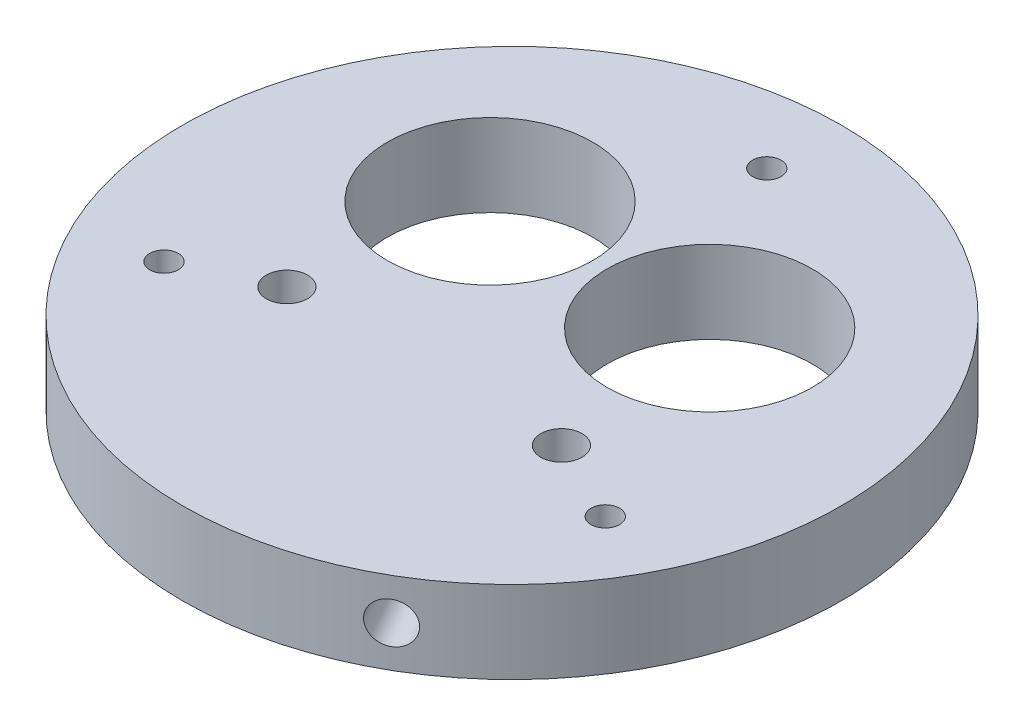
from build123d import *

# Parameters (mm, degrees)
SKETCH1_R               = 38.1127
BOSS_EXTRUDE1_DEPTH     = 9.525
SKETCH2_R               = 1.651
SKETCH2_R_2             = 11.8745
CUT_EXTRUDE1_DEPTH      = 55.734645587
SKETCH4_R               = 2.3749
CUT_EXTRUDE2_DEPTH      = 6.35
CIRPATTERN1_COUNT       = 3
CUT_EXTRUDE3_DEPTH      = 55.734645747
CUT_EXTRUDE3_DEPTH_BACK = 55.734645747
SKETCH5_R               = 2.38125


with BuildPart() as part:
    # Sketch1 → Boss-Extrude1 (new body)
    with BuildSketch(Plane(origin=(0, 0, 0), x_dir=(1, 0, 0), z_dir=(0, 1, 0))):
        Circle(SKETCH1_R)
    extrude(amount=BOSS_EXTRUDE1_DEPTH)

    # Sketch2 → Cut-Extrude1 (cut, through all)
    with BuildSketch(Plane(origin=(0, 9.525, 0), x_dir=(1, 0, 0), z_dir=(0, 1, 0))):
        with Locations((0, 29.464)):
            Circle(SKETCH2_R)
        with Locations((25.516572497, -14.732)):
            Circle(SKETCH2_R)
        with Locations((-25.516572497, -14.732)):
            Circle(SKETCH2_R)
        with Locations((-12.7, 10.16)):
            Circle(SKETCH2_R_2)
        with Locations((12.7, 10.16)):
            Circle(SKETCH2_R_2)
    extrude(amount=-CUT_EXTRUDE1_DEPTH, mode=Mode.SUBTRACT)

    # Sketch4 → Cut-Extrude2 (cut)
    with BuildSketch(Plane(origin=(19.05635, 0, -33.006566407), x_dir=(0, -1, 0), z_dir=(0.499999999999998, 0, -0.8660254037844398))):
        with Locations((-4.7625, 0)):
            Circle(SKETCH4_R)
    cut_extrude2 = extrude(amount=-CUT_EXTRUDE2_DEPTH, mode=Mode.SUBTRACT)

    # CirPattern1: Cut-Extrude2 ×3 about axis
    cirpattern1_axis = Axis((0, 10.00125, 0), (0, -1, 0))
    for i in range(1, CIRPATTERN1_COUNT):
        add(cut_extrude2.rotate(cirpattern1_axis, i * 360 / CIRPATTERN1_COUNT), mode=Mode.SUBTRACT)

    # Sketch5 → Cut-Extrude3 (cut, two sides: drawn at the far end of the back side and taken through both)
    with BuildSketch(Plane(origin=(0, 9.525, 0), x_dir=(1, 0, 0), z_dir=(0, 1, 0)).offset(-CUT_EXTRUDE3_DEPTH_BACK)):
        with Locations((-15.875, -10.16)):
            Circle(SKETCH5_R)
        with Locations((15.875, -10.16)):
            Circle(SKETCH5_R)
    extrude(amount=CUT_EXTRUDE3_DEPTH + CUT_EXTRUDE3_DEPTH_BACK, mode=Mode.SUBTRACT)


solid = part.part
